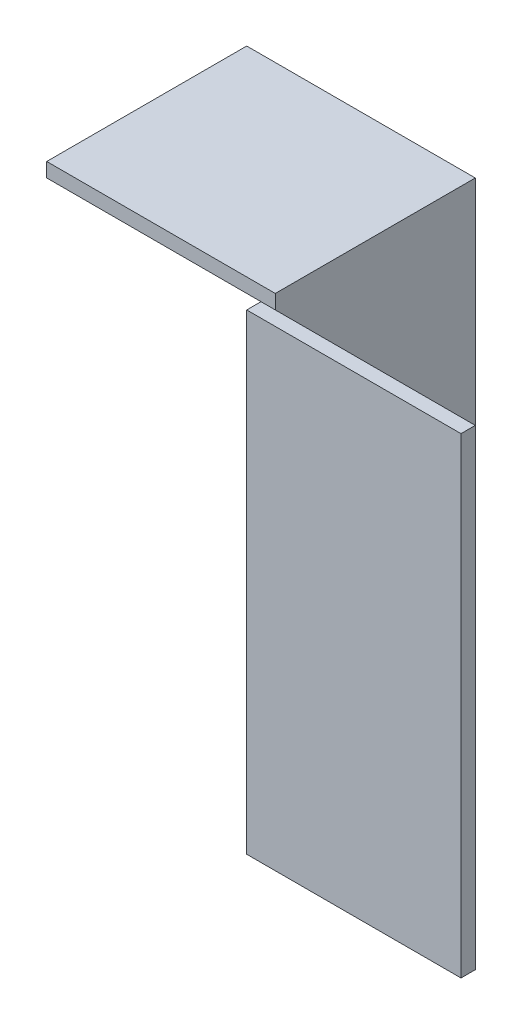
from build123d import *

# Parameters (mm, degrees)
EXTRUDE_1_DEPTH     = 53
CUT_EXTRUDE_2_DEPTH = 20
SKETCH_6_W          = 14
SKETCH_6_H          = 1
EXTRUDE_2_DEPTH     = 16


with BuildPart() as part:
    # Эскиз1 → Бобышка-Вытянуть1 (new body)
    with BuildSketch(Plane(origin=(0, 0, 0), x_dir=(1, 0, 0), z_dir=(0, 1, 0))):
        Polygon((0, 0), (0, 15), (1, 15), (1, 1), (15, 1), (15, 0), align=None)
    extrude(amount=EXTRUDE_1_DEPTH)

    # Эскиз5 → Вырез-Вытянуть2 (cut)
    with BuildSketch(Plane(origin=(0, 53, 0), x_dir=(1, 0, 0), z_dir=(0, 1, 0))):
        Polygon((0, 0), (15, 0), (15, 1), (1, 1), (1, 15), (0, 15), align=None)
    extrude(amount=-CUT_EXTRUDE_2_DEPTH, mode=Mode.SUBTRACT)

    # Эскиз6 → Бобышка-Вытянуть2 (add)
    with BuildSketch(Plane(origin=(1, 0, 0), x_dir=(0, 0, -1), z_dir=(1, 0, 0))):
        with Locations((8, 33.5)):
            Rectangle(SKETCH_6_W, SKETCH_6_H)
    extrude(amount=-EXTRUDE_2_DEPTH)


solid = part.part
